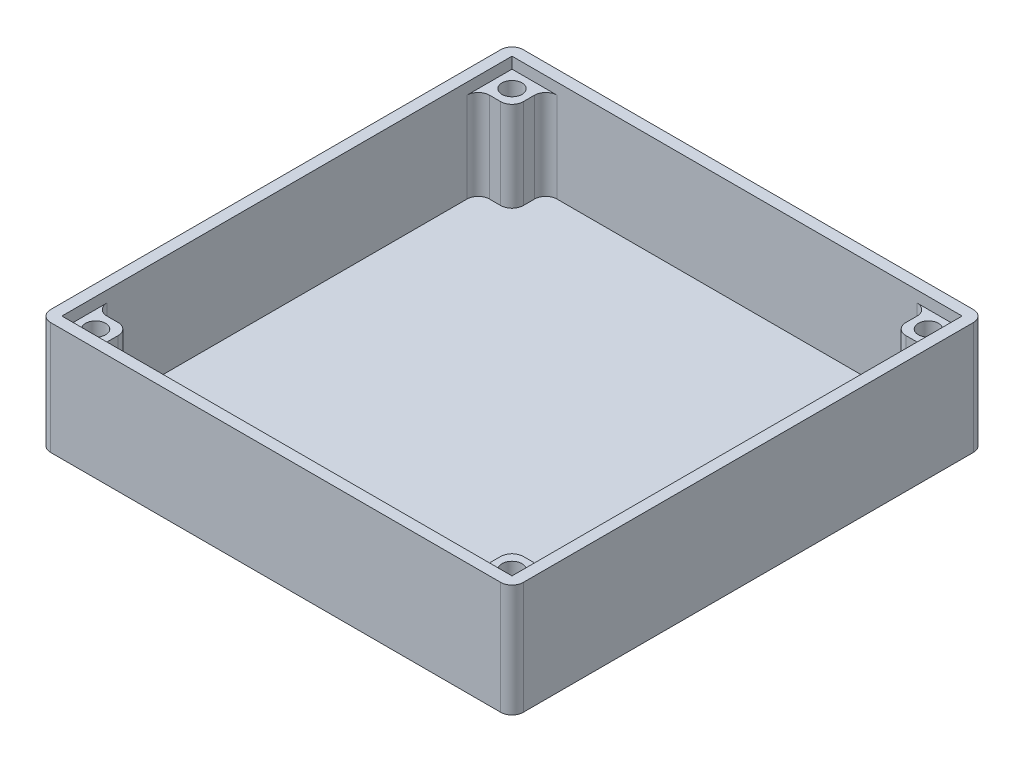
from build123d import *

# Parameters (mm, degrees)
SKETCH4_W                 = 53.34
SKETCH4_H                 = 53.34
BOSS_EXTRUDE1_DEPTH       = 12.7
CUT_EXTRUDE1_DEPTH        = 11.43
F_4_40_TAPPED_HOLE1_D     = 2.2606
F_4_40_TAPPED_HOLE1_DEPTH = 11.43
SKETCH5_W                 = 50.8
SKETCH5_H                 = 50.8
CUT_EXTRUDE2_DEPTH        = 1.27
FILLET1_R                 = 1.27


with BuildPart() as part:
    # Sketch4 → Boss-Extrude1 (new body)
    with BuildSketch(Plane(origin=(0, 0, 0), x_dir=(1, 0, 0), z_dir=(0, 1, 0))):
        with Locations((25.4, 25.4)):
            Rectangle(SKETCH4_W, SKETCH4_H)
    extrude(amount=-BOSS_EXTRUDE1_DEPTH)

    # Sketch3 → Cut-Extrude1 (cut)
    with BuildSketch(Plane(origin=(0, 0, 0), x_dir=(1, 0, 0), z_dir=(0, 1, 0))):
        with BuildLine():
            Line((5.08, 0), (45.72, 0))
            ThreePointArc((45.72, 0), (46.618025612, 0.371974388), (46.99, 1.27))
            Line((46.99, 1.27), (46.99, 2.54))
            ThreePointArc((46.99, 2.54), (47.361974388, 3.438025612), (48.26, 3.81))
            Line((48.26, 3.81), (49.53, 3.81))
            ThreePointArc((49.53, 3.81), (50.428025612, 4.181974388), (50.8, 5.08))
            Line((50.8, 5.08), (50.8, 45.72))
            ThreePointArc((50.8, 45.72), (50.428025612, 46.618025612), (49.53, 46.99))
            Line((49.53, 46.99), (48.26, 46.99))
            ThreePointArc((48.26, 46.99), (47.361974388, 47.361974388), (46.99, 48.26))
            Line((46.99, 48.26), (46.99, 49.53))
            ThreePointArc((46.99, 49.53), (46.618025612, 50.428025612), (45.72, 50.8))
            Line((45.72, 50.8), (5.08, 50.8))
            ThreePointArc((5.08, 50.8), (4.181974388, 50.428025612), (3.81, 49.53))
            Line((3.81, 49.53), (3.81, 48.26))
            ThreePointArc((3.81, 48.26), (3.438025612, 47.361974388), (2.54, 46.99))
            Line((2.54, 46.99), (1.27, 46.99))
            ThreePointArc((1.27, 46.99), (0.371974388, 46.618025612), (0, 45.72))
            Line((0, 45.72), (0, 5.08))
            ThreePointArc((0, 5.08), (0.371974388, 4.181974388), (1.27, 3.81))
            Line((1.27, 3.81), (2.54, 3.81))
            ThreePointArc((2.54, 3.81), (3.438025612, 3.438025612), (3.81, 2.54))
            Line((3.81, 2.54), (3.81, 1.27))
            ThreePointArc((3.81, 1.27), (4.181974388, 0.371974388), (5.08, 0))
        make_face()
    extrude(amount=-CUT_EXTRUDE1_DEPTH, mode=Mode.SUBTRACT)

    # #4-40 Tapped Hole1
    with Locations(Plane(origin=(0, 0, 0), x_dir=(1, 0, 0), z_dir=(0, 1, 0))):
        with Locations((1.905, 48.895), (48.895, 48.895), (1.905, 1.905), (48.895, 1.905)):
            Hole(F_4_40_TAPPED_HOLE1_D / 2, depth=F_4_40_TAPPED_HOLE1_DEPTH)

    # Sketch5 → Cut-Extrude2 (cut)
    with BuildSketch(Plane(origin=(0, 0, 0), x_dir=(1, 0, 0), z_dir=(0, 1, 0))):
        with Locations((25.4, 25.4)):
            Rectangle(SKETCH5_W, SKETCH5_H)
    extrude(amount=-CUT_EXTRUDE2_DEPTH, mode=Mode.SUBTRACT)

    # Fillet1
    fillet1_edges = [part.edges().sort_by_distance(p)[0] for p in [
        (-1.27, -6.35, -52.07),
        (52.07, -6.35, -52.07),
        (52.07, -6.35, 1.27),
        (-1.27, -6.35, 1.27),
    ]]
    fillet(fillet1_edges, radius=FILLET1_R)


solid = part.part
